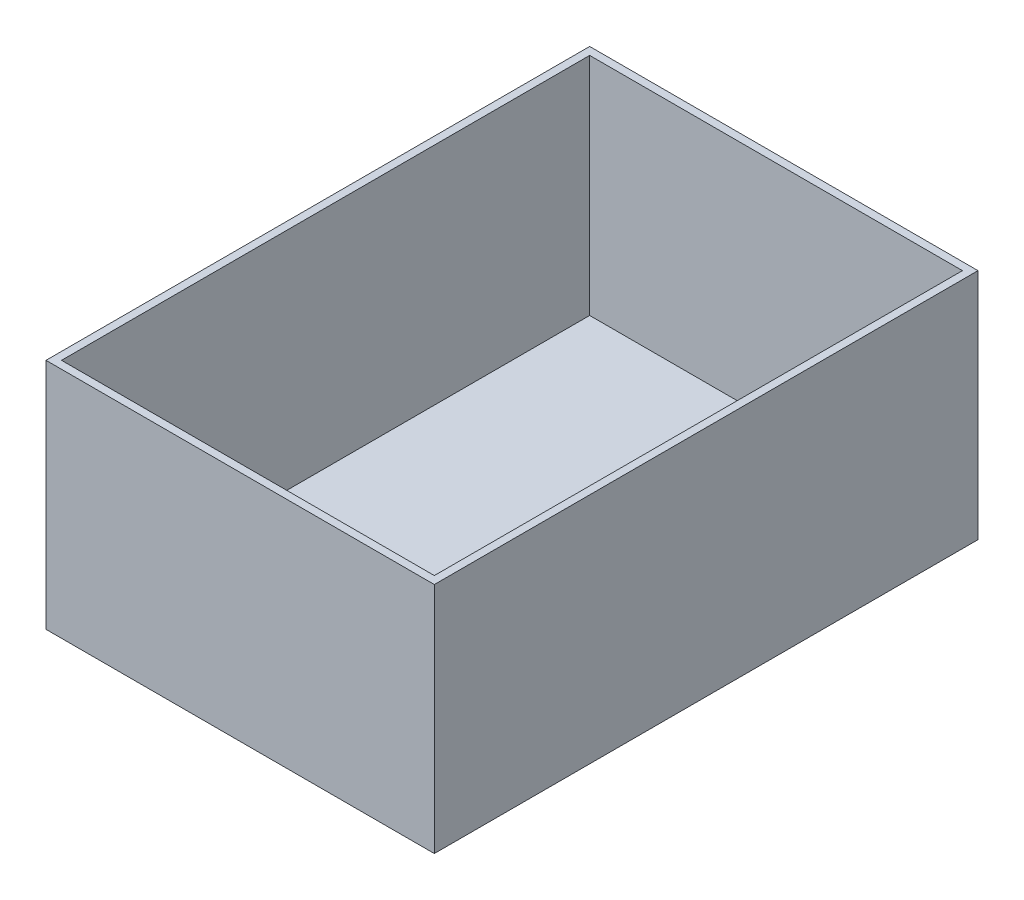
from build123d import *

# Parameters (mm, degrees)
SKETCH4_W           = 250
SKETCH4_H           = 350
BOSS_EXTRUDE2_DEPTH = 150
SHELL1_T            = -5


with BuildPart() as part:
    # Sketch4 → Boss-Extrude2 (new body)
    with BuildSketch(Plane(origin=(0, 0, 0), x_dir=(1, 0, 0), z_dir=(0, 1, 0))):
        with Locations((-125, 175)):
            Rectangle(SKETCH4_W, SKETCH4_H)
    extrude(amount=BOSS_EXTRUDE2_DEPTH)

    # Shell1
    shell1_openings = [part.faces().sort_by_distance(p)[0] for p in [
        (-125, 150, -175),
    ]]
    offset(amount=SHELL1_T, openings=shell1_openings, kind=Kind.INTERSECTION)


solid = part.part
